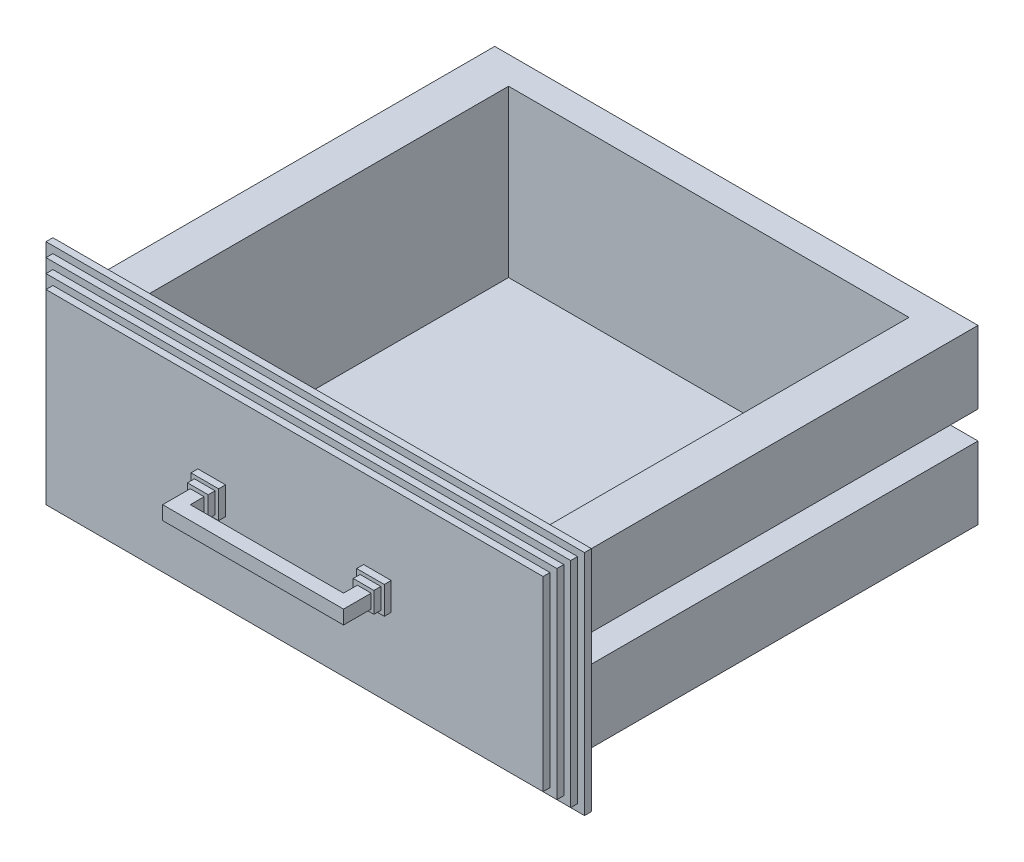
from build123d import *

# Parameters (mm, degrees)
BOSS_EXTRUDE1_DEPTH = 320
SKETCH2_W           = 20
SKETCH2_H           = 20
BOSS_EXTRUDE2_DEPTH = 5
SKETCH3_W           = 15
SKETCH3_H           = 15
BOSS_EXTRUDE3_DEPTH = 5
SKETCH4_W           = 10
SKETCH4_H           = 10
BOSS_EXTRUDE4_DEPTH = 20
BOSS_EXTRUDE5_REACH = 232.496
SKETCH5_W           = 10
SKETCH5_H           = 10
SKETCH6_W           = 290
SKETCH6_H           = 280
CUT_EXTRUDE1_DEPTH  = 120
SKETCH7_W           = 360
SKETCH7_H           = 135
BOSS_EXTRUDE6_DEPTH = 5
SKETCH8_W           = 370
SKETCH8_H           = 145
BOSS_EXTRUDE7_DEPTH = 5
SKETCH9_W           = 380
SKETCH9_H           = 155
BOSS_EXTRUDE8_DEPTH = 5
SKETCH10_W          = 390
SKETCH10_H          = 165
BOSS_EXTRUDE9_DEPTH = 5


with BuildPart() as part:
    # Sketch1 → Boss-Extrude1 (new body)
    with BuildSketch(Plane.XY):
        Polygon((-175, 206.36092205), (175, 206.36092205), (175, 258.86092205), (155, 258.86092205), (155, 278.86092205), (175, 278.86092205), (175, 331.36092205), (-175, 331.36092205), (-175, 278.86092205), (-155, 278.86092205), (-155, 258.86092205), (-175, 258.86092205), align=None)
    extrude(amount=BOSS_EXTRUDE1_DEPTH)

    # Sketch2 → Boss-Extrude2 (add)
    with BuildSketch(Plane.XY.offset(320)):
        with Locations((60, 268.86092205)):
            Rectangle(SKETCH2_W, SKETCH2_H)
        with Locations((-60, 268.86092205)):
            Rectangle(SKETCH2_W, SKETCH2_H)
    extrude(amount=BOSS_EXTRUDE2_DEPTH)

    # Sketch3 → Boss-Extrude3 (add)
    with BuildSketch(Plane.XY.offset(325)):
        with Locations((60, 268.86092205)):
            Rectangle(SKETCH3_W, SKETCH3_H)
        with Locations((-60, 268.86092205)):
            Rectangle(SKETCH3_W, SKETCH3_H)
    extrude(amount=BOSS_EXTRUDE3_DEPTH)

    # Sketch4 → Boss-Extrude4 (add)
    with BuildSketch(Plane.XY.offset(330)):
        with Locations((60.496067434, 268.65644762)):
            Rectangle(SKETCH4_W, SKETCH4_H)
        with Locations((-60.496067434, 268.65644762)):
            Rectangle(SKETCH4_W, SKETCH4_H)
    extrude(amount=BOSS_EXTRUDE4_DEPTH)

    # Sketch5 → Boss-Extrude5 (add, up to next)
    with BuildSketch(Plane.ZY.offset(-55.496067434), mode=Mode.PRIVATE) as boss_extrude5_sk1:
        with Locations((345, 268.65644762)):
            Rectangle(SKETCH5_W, SKETCH5_H)
    boss_extrude5_tool1 = extrude(boss_extrude5_sk1.sketch, amount=BOSS_EXTRUDE5_REACH, mode=Mode.PRIVATE) - part.part
    add(boss_extrude5_tool1.solids().sort_by_distance((55.496067, 268.656448, 345))[0])

    # Sketch6 → Cut-Extrude1 (cut)
    with BuildSketch(Plane(origin=(0, 331.36092205, 0), x_dir=(1, 0, 0), z_dir=(0, 1, 0))):
        with Locations((0, -160)):
            Rectangle(SKETCH6_W, SKETCH6_H)
    extrude(amount=-CUT_EXTRUDE1_DEPTH, mode=Mode.SUBTRACT)

    # Sketch7 → Boss-Extrude6 (add)
    with BuildSketch(Plane.XY.offset(320)):
        with Locations((0, 268.86092205)):
            Rectangle(SKETCH7_W, SKETCH7_H)
    extrude(amount=-BOSS_EXTRUDE6_DEPTH)

    # Sketch8 → Boss-Extrude7 (add)
    with BuildSketch(Plane(origin=(0, 0, 315), x_dir=(-1, 0, 0), z_dir=(0, 0, -1))):
        with Locations((0, 268.86092205)):
            Rectangle(SKETCH8_W, SKETCH8_H)
    extrude(amount=BOSS_EXTRUDE7_DEPTH)

    # Sketch9 → Boss-Extrude8 (add)
    with BuildSketch(Plane(origin=(0, 0, 310), x_dir=(-1, 0, 0), z_dir=(0, 0, -1))):
        with Locations((0, 268.86092205)):
            Rectangle(SKETCH9_W, SKETCH9_H)
    extrude(amount=BOSS_EXTRUDE8_DEPTH)

    # Sketch10 → Boss-Extrude9 (add)
    with BuildSketch(Plane(origin=(0, 0, 305), x_dir=(-1, 0, 0), z_dir=(0, 0, -1))):
        with Locations((0, 268.86092205)):
            Rectangle(SKETCH10_W, SKETCH10_H)
    extrude(amount=BOSS_EXTRUDE9_DEPTH)


solid = part.part
